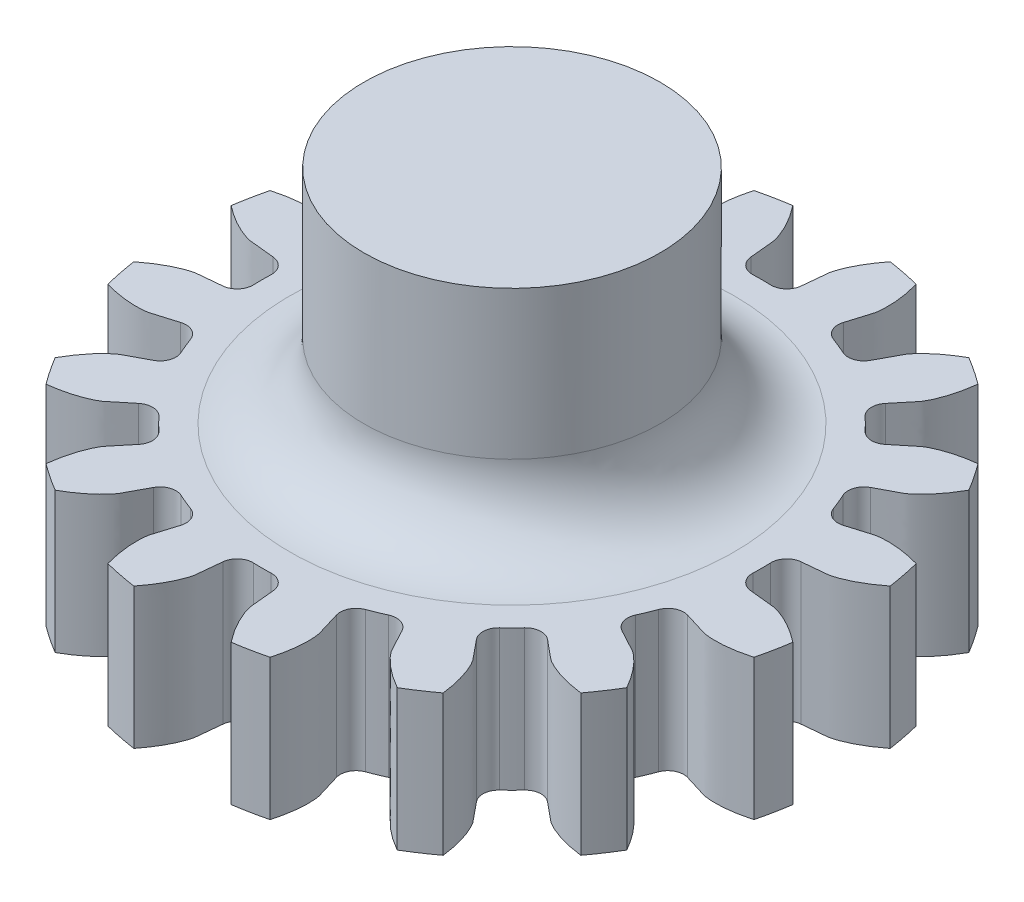
from build123d import *

# Parameters (mm, degrees)
BOSS_EXTRUDE1_DEPTH = 3.8
SKETCH2_R           = 4
SKETCH2_R_2         = 1.75
BOSS_EXTRUDE2_DEPTH = 6
SKETCH3_R           = 4
BOSS_EXTRUDE3_DEPTH = 0.5
FILLET1_R           = 2


with BuildPart() as part:
    # Sketch1 → Boss-Extrude1 (new body)
    with BuildSketch(Plane.XZ.offset(3.8)):
        with BuildLine():
            ThreePointArc((7.133082846, -0.678954432), (6.851906164, -0.535743116), (6.745782453, -0.238577227))
            ThreePointArc((6.745782453, -0.238577227), (6.75, 0), (6.745782453, 0.238577227))
            ThreePointArc((6.745782453, 0.238577227), (6.851906164, 0.535743116), (7.133082846, 0.678954432))
            add(Edge.make_bspline(
                [(7.133082846, 0.678954432), (7.461849238, 0.709527724), (7.794754735, 0.741167195), (7.825696338, 0.748530418), (7.879542254, 0.759899628), (7.943374812, 0.777921992), (8.02764967, 0.805704165), (8.127768783, 0.844604543), (8.243971957, 0.896481426), (8.374799322, 0.962966662), (8.519149122, 1.045576863), (8.675654626, 1.146099469), (8.805388157, 1.238124667), (8.882458095, 1.298015943), (8.903473518, 1.314594733)],
                knots=[0.061705529, 0.061705529, 0.061705529, 0.061705529, 0.215819371, 0.251310953, 0.297130332, 0.351344533, 0.412817651, 0.480778735, 0.55466022, 0.634021663, 0.718508369, 0.807826724, 0.901728446, 0.936889537, 0.936889537, 0.936889537, 0.936889537], degree=3))
            ThreePointArc((8.903473518, 1.314594733), (8.827067524, 1.755812898), (8.728810576, 2.192684638))
            add(Edge.make_bspline(
                [(6.849933857, 2.102440524), (7.16537429, 2.200007936), (7.485046767, 2.298174295), (7.516450864, 2.303212403), (7.570548812, 2.313314562), (7.636419266, 2.321091731), (7.724910859, 2.327674942), (7.832295389, 2.330049605), (7.959505547, 2.326590644), (8.10581707, 2.31523176), (8.270792451, 2.294150163), (8.453853019, 2.261171449), (8.608927691, 2.225798125), (8.703050429, 2.199959189), (8.728810576, 2.192684638)],
                knots=[0.061705529, 0.061705529, 0.061705529, 0.061705529, 0.215819371, 0.251310953, 0.297130332, 0.351344533, 0.412817651, 0.480778735, 0.55466022, 0.634021663, 0.718508369, 0.807826724, 0.901728446, 0.936889537, 0.936889537, 0.936889537, 0.936889537], degree=3))
            ThreePointArc((6.849933857, 2.102440524), (6.535355878, 2.127148869), (6.323589892, 2.361082566))
            ThreePointArc((6.323589892, 2.361082566), (6.236186844, 2.583113168), (6.140990787, 2.8019158))
            ThreePointArc((6.140990787, 2.8019158), (6.125315849, 3.117073069), (6.330284633, 3.35698473))
            add(Edge.make_bspline(
                [(6.330284633, 3.35698473), (6.62232528, 3.51104422), (6.917781954, 3.667672698), (6.943550485, 3.686316268), (6.988946816, 3.717425988), (7.04102355, 3.758504144), (7.108251588, 3.816422117), (7.185863058, 3.890675306), (7.273368368, 3.983072326), (7.368794295, 4.09456214), (7.470542565, 4.22612429), (7.576666462, 4.378887132), (7.661308097, 4.513554202), (7.709592036, 4.598379914), (7.722663327, 4.621738973)],
                knots=[0.061705529, 0.061705529, 0.061705529, 0.061705529, 0.215819371, 0.251310953, 0.297130332, 0.351344533, 0.412817651, 0.480778735, 0.55466022, 0.634021663, 0.718508369, 0.807826724, 0.901728446, 0.936889537, 0.936889537, 0.936889537, 0.936889537], degree=3))
            ThreePointArc((7.722663327, 4.621738973), (7.483226511, 5.000132097), (7.225265351, 5.36614765))
            add(Edge.make_bspline(
                [(5.523944534, 4.563757968), (5.778036061, 4.774612331), (6.03580828, 4.987639581), (6.062893882, 5.004312013), (6.109007941, 5.034347581), (6.166888111, 5.066740279), (6.246124397, 5.106686639), (6.344426022, 5.149974823), (6.46327657, 5.195460379), (6.602797649, 5.240957135), (6.763282604, 5.284613624), (6.945028924, 5.324199511), (7.101836025, 5.350863329), (7.198682228, 5.363010477), (7.225265351, 5.36614765)],
                knots=[0.061705529, 0.061705529, 0.061705529, 0.061705529, 0.215819371, 0.251310953, 0.297130332, 0.351344533, 0.412817651, 0.480778735, 0.55466022, 0.634021663, 0.718508369, 0.807826724, 0.901728446, 0.936889537, 0.936889537, 0.936889537, 0.936889537], degree=3))
            ThreePointArc((5.523944534, 4.563757968), (5.223856903, 4.466201722), (4.938688092, 4.601288942))
            ThreePointArc((4.938688092, 4.601288942), (4.772970773, 4.772970773), (4.601288942, 4.938688092))
            ThreePointArc((4.601288942, 4.938688092), (4.466201722, 5.223856903), (4.563757968, 5.523944534))
            add(Edge.make_bspline(
                [(4.563757968, 5.523944534), (4.774612331, 5.778036061), (4.987639581, 6.03580828), (5.004312013, 6.062893882), (5.034347581, 6.109007941), (5.066740279, 6.166888111), (5.106686639, 6.246124397), (5.149974823, 6.344426022), (5.195460379, 6.46327657), (5.240957135, 6.602797649), (5.284613624, 6.763282604), (5.324199511, 6.945028924), (5.350863329, 7.101836025), (5.363010477, 7.198682228), (5.36614765, 7.225265351)],
                knots=[0.061705529, 0.061705529, 0.061705529, 0.061705529, 0.215819371, 0.251310953, 0.297130332, 0.351344533, 0.412817651, 0.480778735, 0.55466022, 0.634021663, 0.718508369, 0.807826724, 0.901728446, 0.936889537, 0.936889537, 0.936889537, 0.936889537], degree=3))
            ThreePointArc((5.36614765, 7.225265351), (5.000132097, 7.483226511), (4.621738973, 7.722663327))
            add(Edge.make_bspline(
                [(3.35698473, 6.330284633), (3.51104422, 6.62232528), (3.667672698, 6.917781954), (3.686316268, 6.943550485), (3.717425988, 6.988946816), (3.758504144, 7.04102355), (3.816422117, 7.108251588), (3.890675306, 7.185863058), (3.983072326, 7.273368368), (4.09456214, 7.368794295), (4.22612429, 7.470542565), (4.378887132, 7.576666462), (4.513554202, 7.661308097), (4.598379914, 7.709592036), (4.621738973, 7.722663327)],
                knots=[0.061705529, 0.061705529, 0.061705529, 0.061705529, 0.215819371, 0.251310953, 0.297130332, 0.351344533, 0.412817651, 0.480778735, 0.55466022, 0.634021663, 0.718508369, 0.807826724, 0.901728446, 0.936889537, 0.936889537, 0.936889537, 0.936889537], degree=3))
            ThreePointArc((3.35698473, 6.330284633), (3.117073069, 6.125315849), (2.8019158, 6.140990787))
            ThreePointArc((2.8019158, 6.140990787), (2.583113168, 6.236186844), (2.361082566, 6.323589892))
            ThreePointArc((2.361082566, 6.323589892), (2.127148869, 6.535355878), (2.102440524, 6.849933857))
            add(Edge.make_bspline(
                [(2.102440524, 6.849933857), (2.200007936, 7.16537429), (2.298174295, 7.485046767), (2.303212403, 7.516450864), (2.313314562, 7.570548812), (2.321091731, 7.636419266), (2.327674942, 7.724910859), (2.330049605, 7.832295389), (2.326590644, 7.959505547), (2.31523176, 8.10581707), (2.294150163, 8.270792451), (2.261171449, 8.453853019), (2.225798125, 8.608927691), (2.199959189, 8.703050429), (2.192684638, 8.728810576)],
                knots=[0.061705529, 0.061705529, 0.061705529, 0.061705529, 0.215819371, 0.251310953, 0.297130332, 0.351344533, 0.412817651, 0.480778735, 0.55466022, 0.634021663, 0.718508369, 0.807826724, 0.901728446, 0.936889537, 0.936889537, 0.936889537, 0.936889537], degree=3))
            ThreePointArc((2.192684638, 8.728810576), (1.755812898, 8.827067524), (1.314594733, 8.903473518))
            add(Edge.make_bspline(
                [(0.678954432, 7.133082846), (0.709527724, 7.461849238), (0.741167195, 7.794754735), (0.748530418, 7.825696338), (0.759899628, 7.879542254), (0.777921992, 7.943374812), (0.805704165, 8.02764967), (0.844604543, 8.127768783), (0.896481426, 8.243971957), (0.962966662, 8.374799322), (1.045576863, 8.519149122), (1.146099469, 8.675654626), (1.238124667, 8.805388157), (1.298015943, 8.882458095), (1.314594733, 8.903473518)],
                knots=[0.061705529, 0.061705529, 0.061705529, 0.061705529, 0.215819371, 0.251310953, 0.297130332, 0.351344533, 0.412817651, 0.480778735, 0.55466022, 0.634021663, 0.718508369, 0.807826724, 0.901728446, 0.936889537, 0.936889537, 0.936889537, 0.936889537], degree=3))
            ThreePointArc((0.678954432, 7.133082846), (0.535743116, 6.851906164), (0.238577227, 6.745782453))
            ThreePointArc((0.238577227, 6.745782453), (0, 6.75), (-0.238577227, 6.745782453))
            ThreePointArc((-0.238577227, 6.745782453), (-0.535743116, 6.851906164), (-0.678954432, 7.133082846))
            add(Edge.make_bspline(
                [(-0.678954432, 7.133082846), (-0.709527724, 7.461849238), (-0.741167195, 7.794754735), (-0.748530418, 7.825696338), (-0.759899628, 7.879542254), (-0.777921992, 7.943374812), (-0.805704165, 8.02764967), (-0.844604543, 8.127768783), (-0.896481426, 8.243971957), (-0.962966662, 8.374799322), (-1.045576863, 8.519149122), (-1.146099469, 8.675654626), (-1.238124667, 8.805388157), (-1.298015943, 8.882458095), (-1.314594733, 8.903473518)],
                knots=[0.061705529, 0.061705529, 0.061705529, 0.061705529, 0.215819371, 0.251310953, 0.297130332, 0.351344533, 0.412817651, 0.480778735, 0.55466022, 0.634021663, 0.718508369, 0.807826724, 0.901728446, 0.936889537, 0.936889537, 0.936889537, 0.936889537], degree=3))
            ThreePointArc((-1.314594733, 8.903473518), (-1.755812898, 8.827067524), (-2.192684638, 8.728810576))
            add(Edge.make_bspline(
                [(-2.102440524, 6.849933857), (-2.200007936, 7.16537429), (-2.298174295, 7.485046767), (-2.303212403, 7.516450864), (-2.313314562, 7.570548812), (-2.321091731, 7.636419266), (-2.327674942, 7.724910859), (-2.330049605, 7.832295389), (-2.326590644, 7.959505547), (-2.31523176, 8.10581707), (-2.294150163, 8.270792451), (-2.261171449, 8.453853019), (-2.225798125, 8.608927691), (-2.199959189, 8.703050429), (-2.192684638, 8.728810576)],
                knots=[0.061705529, 0.061705529, 0.061705529, 0.061705529, 0.215819371, 0.251310953, 0.297130332, 0.351344533, 0.412817651, 0.480778735, 0.55466022, 0.634021663, 0.718508369, 0.807826724, 0.901728446, 0.936889537, 0.936889537, 0.936889537, 0.936889537], degree=3))
            ThreePointArc((-2.102440524, 6.849933857), (-2.127148869, 6.535355878), (-2.361082566, 6.323589892))
            ThreePointArc((-2.361082566, 6.323589892), (-2.583113168, 6.236186844), (-2.8019158, 6.140990787))
            ThreePointArc((-2.8019158, 6.140990787), (-3.117073069, 6.125315849), (-3.35698473, 6.330284633))
            add(Edge.make_bspline(
                [(-3.35698473, 6.330284633), (-3.51104422, 6.62232528), (-3.667672698, 6.917781954), (-3.686316268, 6.943550485), (-3.717425988, 6.988946816), (-3.758504144, 7.04102355), (-3.816422117, 7.108251588), (-3.890675306, 7.185863058), (-3.983072326, 7.273368368), (-4.09456214, 7.368794295), (-4.22612429, 7.470542565), (-4.378887132, 7.576666462), (-4.513554202, 7.661308097), (-4.598379914, 7.709592036), (-4.621738973, 7.722663327)],
                knots=[0.061705529, 0.061705529, 0.061705529, 0.061705529, 0.215819371, 0.251310953, 0.297130332, 0.351344533, 0.412817651, 0.480778735, 0.55466022, 0.634021663, 0.718508369, 0.807826724, 0.901728446, 0.936889537, 0.936889537, 0.936889537, 0.936889537], degree=3))
            ThreePointArc((-4.621738973, 7.722663327), (-5.000132097, 7.483226511), (-5.36614765, 7.225265351))
            add(Edge.make_bspline(
                [(-4.563757968, 5.523944534), (-4.774612331, 5.778036061), (-4.987639581, 6.03580828), (-5.004312013, 6.062893882), (-5.034347581, 6.109007941), (-5.066740279, 6.166888111), (-5.106686639, 6.246124397), (-5.149974823, 6.344426022), (-5.195460379, 6.46327657), (-5.240957135, 6.602797649), (-5.284613624, 6.763282604), (-5.324199511, 6.945028924), (-5.350863329, 7.101836025), (-5.363010477, 7.198682228), (-5.36614765, 7.225265351)],
                knots=[0.061705529, 0.061705529, 0.061705529, 0.061705529, 0.215819371, 0.251310953, 0.297130332, 0.351344533, 0.412817651, 0.480778735, 0.55466022, 0.634021663, 0.718508369, 0.807826724, 0.901728446, 0.936889537, 0.936889537, 0.936889537, 0.936889537], degree=3))
            ThreePointArc((-4.563757968, 5.523944534), (-4.466201722, 5.223856903), (-4.601288942, 4.938688092))
            ThreePointArc((-4.601288942, 4.938688092), (-4.772970773, 4.772970773), (-4.938688092, 4.601288942))
            ThreePointArc((-4.938688092, 4.601288942), (-5.223856903, 4.466201722), (-5.523944534, 4.563757968))
            add(Edge.make_bspline(
                [(-5.523944534, 4.563757968), (-5.778036061, 4.774612331), (-6.03580828, 4.987639581), (-6.062893882, 5.004312013), (-6.109007941, 5.034347581), (-6.166888111, 5.066740279), (-6.246124397, 5.106686639), (-6.344426022, 5.149974823), (-6.46327657, 5.195460379), (-6.602797649, 5.240957135), (-6.763282604, 5.284613624), (-6.945028924, 5.324199511), (-7.101836025, 5.350863329), (-7.198682228, 5.363010477), (-7.225265351, 5.36614765)],
                knots=[0.061705529, 0.061705529, 0.061705529, 0.061705529, 0.215819371, 0.251310953, 0.297130332, 0.351344533, 0.412817651, 0.480778735, 0.55466022, 0.634021663, 0.718508369, 0.807826724, 0.901728446, 0.936889537, 0.936889537, 0.936889537, 0.936889537], degree=3))
            ThreePointArc((-7.225265351, 5.36614765), (-7.483226511, 5.000132097), (-7.722663327, 4.621738973))
            add(Edge.make_bspline(
                [(-6.330284633, 3.35698473), (-6.62232528, 3.51104422), (-6.917781954, 3.667672698), (-6.943550485, 3.686316268), (-6.988946816, 3.717425988), (-7.04102355, 3.758504144), (-7.108251588, 3.816422117), (-7.185863058, 3.890675306), (-7.273368368, 3.983072326), (-7.368794295, 4.09456214), (-7.470542565, 4.22612429), (-7.576666462, 4.378887132), (-7.661308097, 4.513554202), (-7.709592036, 4.598379914), (-7.722663327, 4.621738973)],
                knots=[0.061705529, 0.061705529, 0.061705529, 0.061705529, 0.215819371, 0.251310953, 0.297130332, 0.351344533, 0.412817651, 0.480778735, 0.55466022, 0.634021663, 0.718508369, 0.807826724, 0.901728446, 0.936889537, 0.936889537, 0.936889537, 0.936889537], degree=3))
            ThreePointArc((-6.330284633, 3.35698473), (-6.125315849, 3.117073069), (-6.140990787, 2.8019158))
            ThreePointArc((-6.140990787, 2.8019158), (-6.236186844, 2.583113168), (-6.323589892, 2.361082566))
            ThreePointArc((-6.323589892, 2.361082566), (-6.535355878, 2.127148869), (-6.849933857, 2.102440524))
            add(Edge.make_bspline(
                [(-6.849933857, 2.102440524), (-7.16537429, 2.200007936), (-7.485046767, 2.298174295), (-7.516450864, 2.303212403), (-7.570548812, 2.313314562), (-7.636419266, 2.321091731), (-7.724910859, 2.327674942), (-7.832295389, 2.330049605), (-7.959505547, 2.326590644), (-8.10581707, 2.31523176), (-8.270792451, 2.294150163), (-8.453853019, 2.261171449), (-8.608927691, 2.225798125), (-8.703050429, 2.199959189), (-8.728810576, 2.192684638)],
                knots=[0.061705529, 0.061705529, 0.061705529, 0.061705529, 0.215819371, 0.251310953, 0.297130332, 0.351344533, 0.412817651, 0.480778735, 0.55466022, 0.634021663, 0.718508369, 0.807826724, 0.901728446, 0.936889537, 0.936889537, 0.936889537, 0.936889537], degree=3))
            ThreePointArc((-8.728810576, 2.192684638), (-8.827067524, 1.755812898), (-8.903473518, 1.314594733))
            add(Edge.make_bspline(
                [(-7.133082846, 0.678954432), (-7.461849238, 0.709527724), (-7.794754735, 0.741167195), (-7.825696338, 0.748530418), (-7.879542254, 0.759899628), (-7.943374812, 0.777921992), (-8.02764967, 0.805704165), (-8.127768783, 0.844604543), (-8.243971957, 0.896481426), (-8.374799322, 0.962966662), (-8.519149122, 1.045576863), (-8.675654626, 1.146099469), (-8.805388157, 1.238124667), (-8.882458095, 1.298015943), (-8.903473518, 1.314594733)],
                knots=[0.061705529, 0.061705529, 0.061705529, 0.061705529, 0.215819371, 0.251310953, 0.297130332, 0.351344533, 0.412817651, 0.480778735, 0.55466022, 0.634021663, 0.718508369, 0.807826724, 0.901728446, 0.936889537, 0.936889537, 0.936889537, 0.936889537], degree=3))
            ThreePointArc((-7.133082846, 0.678954432), (-6.851906164, 0.535743116), (-6.745782453, 0.238577227))
            ThreePointArc((-6.745782453, 0.238577227), (-6.75, 0), (-6.745782453, -0.238577227))
            ThreePointArc((-6.745782453, -0.238577227), (-6.851906164, -0.535743116), (-7.133082846, -0.678954432))
            add(Edge.make_bspline(
                [(-7.133082846, -0.678954432), (-7.461849238, -0.709527724), (-7.794754735, -0.741167195), (-7.825696338, -0.748530418), (-7.879542254, -0.759899628), (-7.943374812, -0.777921992), (-8.02764967, -0.805704165), (-8.127768783, -0.844604543), (-8.243971957, -0.896481426), (-8.374799322, -0.962966662), (-8.519149122, -1.045576863), (-8.675654626, -1.146099469), (-8.805388157, -1.238124667), (-8.882458095, -1.298015943), (-8.903473518, -1.314594733)],
                knots=[0.061705529, 0.061705529, 0.061705529, 0.061705529, 0.215819371, 0.251310953, 0.297130332, 0.351344533, 0.412817651, 0.480778735, 0.55466022, 0.634021663, 0.718508369, 0.807826724, 0.901728446, 0.936889537, 0.936889537, 0.936889537, 0.936889537], degree=3))
            ThreePointArc((-8.903473518, -1.314594733), (-8.827067524, -1.755812898), (-8.728810576, -2.192684638))
            add(Edge.make_bspline(
                [(-6.849933857, -2.102440524), (-7.16537429, -2.200007936), (-7.485046767, -2.298174295), (-7.516450864, -2.303212403), (-7.570548812, -2.313314562), (-7.636419266, -2.321091731), (-7.724910859, -2.327674942), (-7.832295389, -2.330049605), (-7.959505547, -2.326590644), (-8.10581707, -2.31523176), (-8.270792451, -2.294150163), (-8.453853019, -2.261171449), (-8.608927691, -2.225798125), (-8.703050429, -2.199959189), (-8.728810576, -2.192684638)],
                knots=[0.061705529, 0.061705529, 0.061705529, 0.061705529, 0.215819371, 0.251310953, 0.297130332, 0.351344533, 0.412817651, 0.480778735, 0.55466022, 0.634021663, 0.718508369, 0.807826724, 0.901728446, 0.936889537, 0.936889537, 0.936889537, 0.936889537], degree=3))
            ThreePointArc((-6.849933857, -2.102440524), (-6.535355878, -2.127148869), (-6.323589892, -2.361082566))
            ThreePointArc((-6.323589892, -2.361082566), (-6.236186844, -2.583113168), (-6.140990787, -2.8019158))
            ThreePointArc((-6.140990787, -2.8019158), (-6.125315849, -3.117073069), (-6.330284633, -3.35698473))
            add(Edge.make_bspline(
                [(-6.330284633, -3.35698473), (-6.62232528, -3.51104422), (-6.917781954, -3.667672698), (-6.943550485, -3.686316268), (-6.988946816, -3.717425988), (-7.04102355, -3.758504144), (-7.108251588, -3.816422117), (-7.185863058, -3.890675306), (-7.273368368, -3.983072326), (-7.368794295, -4.09456214), (-7.470542565, -4.22612429), (-7.576666462, -4.378887132), (-7.661308097, -4.513554202), (-7.709592036, -4.598379914), (-7.722663327, -4.621738973)],
                knots=[0.061705529, 0.061705529, 0.061705529, 0.061705529, 0.215819371, 0.251310953, 0.297130332, 0.351344533, 0.412817651, 0.480778735, 0.55466022, 0.634021663, 0.718508369, 0.807826724, 0.901728446, 0.936889537, 0.936889537, 0.936889537, 0.936889537], degree=3))
            ThreePointArc((-7.722663327, -4.621738973), (-7.483226511, -5.000132097), (-7.225265351, -5.36614765))
            add(Edge.make_bspline(
                [(-5.523944534, -4.563757968), (-5.778036061, -4.774612331), (-6.03580828, -4.987639581), (-6.062893882, -5.004312013), (-6.109007941, -5.034347581), (-6.166888111, -5.066740279), (-6.246124397, -5.106686639), (-6.344426022, -5.149974823), (-6.46327657, -5.195460379), (-6.602797649, -5.240957135), (-6.763282604, -5.284613624), (-6.945028924, -5.324199511), (-7.101836025, -5.350863329), (-7.198682228, -5.363010477), (-7.225265351, -5.36614765)],
                knots=[0.061705529, 0.061705529, 0.061705529, 0.061705529, 0.215819371, 0.251310953, 0.297130332, 0.351344533, 0.412817651, 0.480778735, 0.55466022, 0.634021663, 0.718508369, 0.807826724, 0.901728446, 0.936889537, 0.936889537, 0.936889537, 0.936889537], degree=3))
            ThreePointArc((-5.523944534, -4.563757968), (-5.223856903, -4.466201722), (-4.938688092, -4.601288942))
            ThreePointArc((-4.938688092, -4.601288942), (-4.772970773, -4.772970773), (-4.601288942, -4.938688092))
            ThreePointArc((-4.601288942, -4.938688092), (-4.466201722, -5.223856903), (-4.563757968, -5.523944534))
            add(Edge.make_bspline(
                [(-4.563757968, -5.523944534), (-4.774612331, -5.778036061), (-4.987639581, -6.03580828), (-5.004312013, -6.062893882), (-5.034347581, -6.109007941), (-5.066740279, -6.166888111), (-5.106686639, -6.246124397), (-5.149974823, -6.344426022), (-5.195460379, -6.46327657), (-5.240957135, -6.602797649), (-5.284613624, -6.763282604), (-5.324199511, -6.945028924), (-5.350863329, -7.101836025), (-5.363010477, -7.198682228), (-5.36614765, -7.225265351)],
                knots=[0.061705529, 0.061705529, 0.061705529, 0.061705529, 0.215819371, 0.251310953, 0.297130332, 0.351344533, 0.412817651, 0.480778735, 0.55466022, 0.634021663, 0.718508369, 0.807826724, 0.901728446, 0.936889537, 0.936889537, 0.936889537, 0.936889537], degree=3))
            ThreePointArc((-5.36614765, -7.225265351), (-5.000132097, -7.483226511), (-4.621738973, -7.722663327))
            add(Edge.make_bspline(
                [(-3.35698473, -6.330284633), (-3.51104422, -6.62232528), (-3.667672698, -6.917781954), (-3.686316268, -6.943550485), (-3.717425988, -6.988946816), (-3.758504144, -7.04102355), (-3.816422117, -7.108251588), (-3.890675306, -7.185863058), (-3.983072326, -7.273368368), (-4.09456214, -7.368794295), (-4.22612429, -7.470542565), (-4.378887132, -7.576666462), (-4.513554202, -7.661308097), (-4.598379914, -7.709592036), (-4.621738973, -7.722663327)],
                knots=[0.061705529, 0.061705529, 0.061705529, 0.061705529, 0.215819371, 0.251310953, 0.297130332, 0.351344533, 0.412817651, 0.480778735, 0.55466022, 0.634021663, 0.718508369, 0.807826724, 0.901728446, 0.936889537, 0.936889537, 0.936889537, 0.936889537], degree=3))
            ThreePointArc((-3.35698473, -6.330284633), (-3.117073069, -6.125315849), (-2.8019158, -6.140990787))
            ThreePointArc((-2.8019158, -6.140990787), (-2.583113168, -6.236186844), (-2.361082566, -6.323589892))
            ThreePointArc((-2.361082566, -6.323589892), (-2.127148869, -6.535355878), (-2.102440524, -6.849933857))
            add(Edge.make_bspline(
                [(-2.102440524, -6.849933857), (-2.200007936, -7.16537429), (-2.298174295, -7.485046767), (-2.303212403, -7.516450864), (-2.313314562, -7.570548812), (-2.321091731, -7.636419266), (-2.327674942, -7.724910859), (-2.330049605, -7.832295389), (-2.326590644, -7.959505547), (-2.31523176, -8.10581707), (-2.294150163, -8.270792451), (-2.261171449, -8.453853019), (-2.225798125, -8.608927691), (-2.199959189, -8.703050429), (-2.192684638, -8.728810576)],
                knots=[0.061705529, 0.061705529, 0.061705529, 0.061705529, 0.215819371, 0.251310953, 0.297130332, 0.351344533, 0.412817651, 0.480778735, 0.55466022, 0.634021663, 0.718508369, 0.807826724, 0.901728446, 0.936889537, 0.936889537, 0.936889537, 0.936889537], degree=3))
            ThreePointArc((-2.192684638, -8.728810576), (-1.755812898, -8.827067524), (-1.314594733, -8.903473518))
            add(Edge.make_bspline(
                [(-0.678954432, -7.133082846), (-0.709527724, -7.461849238), (-0.741167195, -7.794754735), (-0.748530418, -7.825696338), (-0.759899628, -7.879542254), (-0.777921992, -7.943374812), (-0.805704165, -8.02764967), (-0.844604543, -8.127768783), (-0.896481426, -8.243971957), (-0.962966662, -8.374799322), (-1.045576863, -8.519149122), (-1.146099469, -8.675654626), (-1.238124667, -8.805388157), (-1.298015943, -8.882458095), (-1.314594733, -8.903473518)],
                knots=[0.061705529, 0.061705529, 0.061705529, 0.061705529, 0.215819371, 0.251310953, 0.297130332, 0.351344533, 0.412817651, 0.480778735, 0.55466022, 0.634021663, 0.718508369, 0.807826724, 0.901728446, 0.936889537, 0.936889537, 0.936889537, 0.936889537], degree=3))
            ThreePointArc((-0.678954432, -7.133082846), (-0.535743116, -6.851906164), (-0.238577227, -6.745782453))
            ThreePointArc((-0.238577227, -6.745782453), (0, -6.75), (0.238577227, -6.745782453))
            ThreePointArc((0.238577227, -6.745782453), (0.535743116, -6.851906164), (0.678954432, -7.133082846))
            add(Edge.make_bspline(
                [(0.678954432, -7.133082846), (0.709527724, -7.461849238), (0.741167195, -7.794754735), (0.748530418, -7.825696338), (0.759899628, -7.879542254), (0.777921992, -7.943374812), (0.805704165, -8.02764967), (0.844604543, -8.127768783), (0.896481426, -8.243971957), (0.962966662, -8.374799322), (1.045576863, -8.519149122), (1.146099469, -8.675654626), (1.238124667, -8.805388157), (1.298015943, -8.882458095), (1.314594733, -8.903473518)],
                knots=[0.061705529, 0.061705529, 0.061705529, 0.061705529, 0.215819371, 0.251310953, 0.297130332, 0.351344533, 0.412817651, 0.480778735, 0.55466022, 0.634021663, 0.718508369, 0.807826724, 0.901728446, 0.936889537, 0.936889537, 0.936889537, 0.936889537], degree=3))
            ThreePointArc((1.314594733, -8.903473518), (1.755812898, -8.827067524), (2.192684638, -8.728810576))
            add(Edge.make_bspline(
                [(2.102440524, -6.849933857), (2.200007936, -7.16537429), (2.298174295, -7.485046767), (2.303212403, -7.516450864), (2.313314562, -7.570548812), (2.321091731, -7.636419266), (2.327674942, -7.724910859), (2.330049605, -7.832295389), (2.326590644, -7.959505547), (2.31523176, -8.10581707), (2.294150163, -8.270792451), (2.261171449, -8.453853019), (2.225798125, -8.608927691), (2.199959189, -8.703050429), (2.192684638, -8.728810576)],
                knots=[0.061705529, 0.061705529, 0.061705529, 0.061705529, 0.215819371, 0.251310953, 0.297130332, 0.351344533, 0.412817651, 0.480778735, 0.55466022, 0.634021663, 0.718508369, 0.807826724, 0.901728446, 0.936889537, 0.936889537, 0.936889537, 0.936889537], degree=3))
            ThreePointArc((2.102440524, -6.849933857), (2.127148869, -6.535355878), (2.361082566, -6.323589892))
            ThreePointArc((2.361082566, -6.323589892), (2.583113168, -6.236186844), (2.8019158, -6.140990787))
            ThreePointArc((2.8019158, -6.140990787), (3.117073069, -6.125315849), (3.35698473, -6.330284633))
            add(Edge.make_bspline(
                [(3.35698473, -6.330284633), (3.51104422, -6.62232528), (3.667672698, -6.917781954), (3.686316268, -6.943550485), (3.717425988, -6.988946816), (3.758504144, -7.04102355), (3.816422117, -7.108251588), (3.890675306, -7.185863058), (3.983072326, -7.273368368), (4.09456214, -7.368794295), (4.22612429, -7.470542565), (4.378887132, -7.576666462), (4.513554202, -7.661308097), (4.598379914, -7.709592036), (4.621738973, -7.722663327)],
                knots=[0.061705529, 0.061705529, 0.061705529, 0.061705529, 0.215819371, 0.251310953, 0.297130332, 0.351344533, 0.412817651, 0.480778735, 0.55466022, 0.634021663, 0.718508369, 0.807826724, 0.901728446, 0.936889537, 0.936889537, 0.936889537, 0.936889537], degree=3))
            ThreePointArc((4.621738973, -7.722663327), (5.000132097, -7.483226511), (5.36614765, -7.225265351))
            add(Edge.make_bspline(
                [(4.563757968, -5.523944534), (4.774612331, -5.778036061), (4.987639581, -6.03580828), (5.004312013, -6.062893882), (5.034347581, -6.109007941), (5.066740279, -6.166888111), (5.106686639, -6.246124397), (5.149974823, -6.344426022), (5.195460379, -6.46327657), (5.240957135, -6.602797649), (5.284613624, -6.763282604), (5.324199511, -6.945028924), (5.350863329, -7.101836025), (5.363010477, -7.198682228), (5.36614765, -7.225265351)],
                knots=[0.061705529, 0.061705529, 0.061705529, 0.061705529, 0.215819371, 0.251310953, 0.297130332, 0.351344533, 0.412817651, 0.480778735, 0.55466022, 0.634021663, 0.718508369, 0.807826724, 0.901728446, 0.936889537, 0.936889537, 0.936889537, 0.936889537], degree=3))
            ThreePointArc((4.563757968, -5.523944534), (4.466201722, -5.223856903), (4.601288942, -4.938688092))
            ThreePointArc((4.601288942, -4.938688092), (4.772970773, -4.772970773), (4.938688092, -4.601288942))
            ThreePointArc((4.938688092, -4.601288942), (5.223856903, -4.466201722), (5.523944534, -4.563757968))
            add(Edge.make_bspline(
                [(5.523944534, -4.563757968), (5.778036061, -4.774612331), (6.03580828, -4.987639581), (6.062893882, -5.004312013), (6.109007941, -5.034347581), (6.166888111, -5.066740279), (6.246124397, -5.106686639), (6.344426022, -5.149974823), (6.46327657, -5.195460379), (6.602797649, -5.240957135), (6.763282604, -5.284613624), (6.945028924, -5.324199511), (7.101836025, -5.350863329), (7.198682228, -5.363010477), (7.225265351, -5.36614765)],
                knots=[0.061705529, 0.061705529, 0.061705529, 0.061705529, 0.215819371, 0.251310953, 0.297130332, 0.351344533, 0.412817651, 0.480778735, 0.55466022, 0.634021663, 0.718508369, 0.807826724, 0.901728446, 0.936889537, 0.936889537, 0.936889537, 0.936889537], degree=3))
            ThreePointArc((7.225265351, -5.36614765), (7.483226511, -5.000132097), (7.722663327, -4.621738973))
            add(Edge.make_bspline(
                [(6.330284633, -3.35698473), (6.62232528, -3.51104422), (6.917781954, -3.667672698), (6.943550485, -3.686316268), (6.988946816, -3.717425988), (7.04102355, -3.758504144), (7.108251588, -3.816422117), (7.185863058, -3.890675306), (7.273368368, -3.983072326), (7.368794295, -4.09456214), (7.470542565, -4.22612429), (7.576666462, -4.378887132), (7.661308097, -4.513554202), (7.709592036, -4.598379914), (7.722663327, -4.621738973)],
                knots=[0.061705529, 0.061705529, 0.061705529, 0.061705529, 0.215819371, 0.251310953, 0.297130332, 0.351344533, 0.412817651, 0.480778735, 0.55466022, 0.634021663, 0.718508369, 0.807826724, 0.901728446, 0.936889537, 0.936889537, 0.936889537, 0.936889537], degree=3))
            ThreePointArc((6.330284633, -3.35698473), (6.125315849, -3.117073069), (6.140990787, -2.8019158))
            ThreePointArc((6.140990787, -2.8019158), (6.236186844, -2.583113168), (6.323589892, -2.361082566))
            ThreePointArc((6.323589892, -2.361082566), (6.535355878, -2.127148869), (6.849933857, -2.102440524))
            add(Edge.make_bspline(
                [(6.849933857, -2.102440524), (7.16537429, -2.200007936), (7.485046767, -2.298174295), (7.516450864, -2.303212403), (7.570548812, -2.313314562), (7.636419266, -2.321091731), (7.724910859, -2.327674942), (7.832295389, -2.330049605), (7.959505547, -2.326590644), (8.10581707, -2.31523176), (8.270792451, -2.294150163), (8.453853019, -2.261171449), (8.608927691, -2.225798125), (8.703050429, -2.199959189), (8.728810576, -2.192684638)],
                knots=[0.061705529, 0.061705529, 0.061705529, 0.061705529, 0.215819371, 0.251310953, 0.297130332, 0.351344533, 0.412817651, 0.480778735, 0.55466022, 0.634021663, 0.718508369, 0.807826724, 0.901728446, 0.936889537, 0.936889537, 0.936889537, 0.936889537], degree=3))
            ThreePointArc((8.728810576, -2.192684638), (8.827067524, -1.755812898), (8.903473518, -1.314594733))
            add(Edge.make_bspline(
                [(7.133082846, -0.678954432), (7.461849238, -0.709527724), (7.794754735, -0.741167195), (7.825696338, -0.748530418), (7.879542254, -0.759899628), (7.943374812, -0.777921992), (8.02764967, -0.805704165), (8.127768783, -0.844604543), (8.243971957, -0.896481426), (8.374799322, -0.962966662), (8.519149122, -1.045576863), (8.675654626, -1.146099469), (8.805388157, -1.238124667), (8.882458095, -1.298015943), (8.903473518, -1.314594733)],
                knots=[0.061705529, 0.061705529, 0.061705529, 0.061705529, 0.215819371, 0.251310953, 0.297130332, 0.351344533, 0.412817651, 0.480778735, 0.55466022, 0.634021663, 0.718508369, 0.807826724, 0.901728446, 0.936889537, 0.936889537, 0.936889537, 0.936889537], degree=3))
        make_face()
        with BuildLine():
            Line((1.32, -1.148956048), (-1.32, -1.148956048))
            ThreePointArc((-1.32, -1.148956048), (0, 1.75), (1.32, -1.148956048))
        make_face(mode=Mode.SUBTRACT)
    extrude(amount=-BOSS_EXTRUDE1_DEPTH)

    # Sketch2 → Boss-Extrude2 (add)
    with BuildSketch(Plane(origin=(0, 0, 0), x_dir=(1, 0, 0), z_dir=(0, 1, 0))):
        Circle(SKETCH2_R)
        Circle(SKETCH2_R_2, mode=Mode.SUBTRACT)
    extrude(amount=BOSS_EXTRUDE2_DEPTH)

    # Sketch3 → Boss-Extrude3 (add)
    with BuildSketch(Plane(origin=(0, 6, 0), x_dir=(1, 0, 0), z_dir=(0, 1, 0))):
        Circle(SKETCH3_R)
    extrude(amount=-BOSS_EXTRUDE3_DEPTH)

    # Fillet1
    fillet1_edges = [part.edges().sort_by_distance(p)[0] for p in [
        (-4, 0, 0),
    ]]
    fillet(fillet1_edges, radius=FILLET1_R)


solid = part.part
